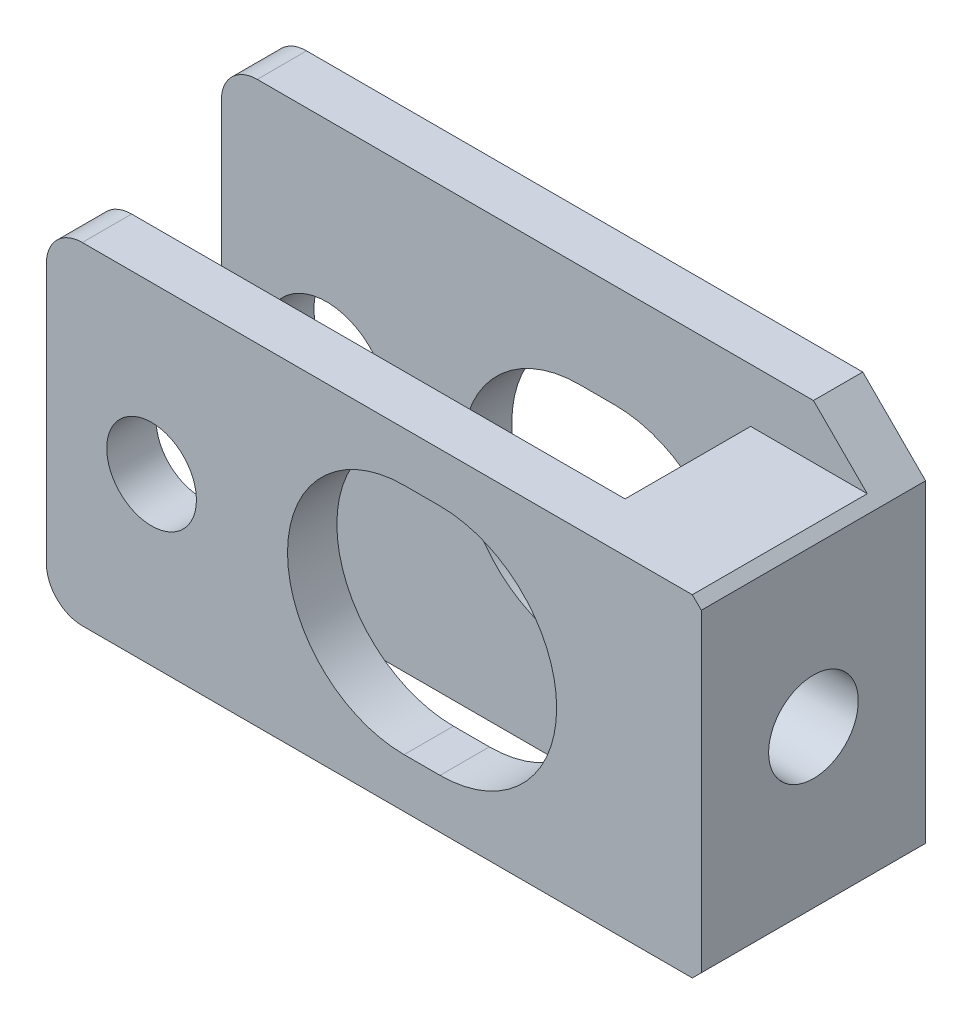
from build123d import *

# Parameters (mm, degrees)
SKETCH1_W           = 36.5
SKETCH1_H           = 18.5
SKETCH1_R           = 3.45
BOSS_EXTRUDE1_DEPTH = 12.5
SKETCH2_W           = 29.5
SKETCH2_H           = 7
CUT_EXTRUDE1_DEPTH  = 19.5
SKETCH3_R           = 3.45
SKETCH3_R_2         = 2.5
BOSS_EXTRUDE3_DEPTH = 2.75
SKETCH4_W           = 36.5
SKETCH4_H           = 2.75
BOSS_EXTRUDE4_DEPTH = 3
SKETCH5_W           = 36.5
SKETCH5_H           = 2.75
BOSS_EXTRUDE5_DEPTH = 3
CHAMFER1_SIZE       = 3.5
CHAMFER3_SIZE       = 3.5
CUT_EXTRUDE2_DEPTH  = 3
SKETCH7_R           = 2.5
CUT_EXTRUDE3_DEPTH  = 5
FILLET1_R           = 2


with BuildPart() as part:
    # Sketch1 → Boss-Extrude1 (new body)
    with BuildSketch(Plane.XY):
        with Locations((252.305597075, 227.81595418)):
            Rectangle(SKETCH1_W, SKETCH1_H)
        with Locations((239.915979082, 227.815953297)):
            Circle(SKETCH1_R, mode=Mode.SUBTRACT)
        with BuildLine():
            Line((253.99332378, 221.31595418), (255.99332378, 221.31595418))
            ThreePointArc((255.99332378, 221.31595418), (262.49332378, 227.81595418), (255.99332378, 234.31595418))
            Line((255.99332378, 234.31595418), (253.99332378, 234.31595418))
            ThreePointArc((253.99332378, 234.31595418), (247.49332378, 227.81595418), (253.99332378, 221.31595418))
        make_face(mode=Mode.SUBTRACT)
    extrude(amount=BOSS_EXTRUDE1_DEPTH)

    # Sketch2 → Cut-Extrude1 (cut, through all)
    with BuildSketch(Plane(origin=(0, 237.06595418, 0), x_dir=(1, 0, 0), z_dir=(0, 1, 0))):
        with Locations((248.805597075, -6.25)):
            Rectangle(SKETCH2_W, SKETCH2_H)
    extrude(amount=-CUT_EXTRUDE1_DEPTH, mode=Mode.SUBTRACT)

    # Sketch3 → Boss-Extrude3 (add)
    with BuildSketch(Plane.XY.offset(12.5)):
        with Locations((239.915979082, 227.815953297)):
            Circle(SKETCH3_R)
        with Locations((239.915979082, 227.815953297)):
            Circle(SKETCH3_R_2, mode=Mode.SUBTRACT)
    extrude(amount=-BOSS_EXTRUDE3_DEPTH)

    # Sketch4 → Boss-Extrude4 (add)
    with BuildSketch(Plane(origin=(0, 237.06595418, 0), x_dir=(1, 0, 0), z_dir=(0, 1, 0))):
        with Locations((252.305597075, -1.375)):
            Rectangle(SKETCH4_W, SKETCH4_H)
    extrude(amount=BOSS_EXTRUDE4_DEPTH)

    # Sketch5 → Boss-Extrude5 (add)
    with BuildSketch(Plane.XZ.offset(-218.56595418)):
        with Locations((252.305597075, 1.375)):
            Rectangle(SKETCH5_W, SKETCH5_H)
    extrude(amount=BOSS_EXTRUDE5_DEPTH)

    # Chamfer1
    chamfer1_edges = [part.edges().sort_by_distance(p)[0] for p in [
        (270.555597075, 215.56595418, 1.375),
    ]]
    chamfer(chamfer1_edges, length=CHAMFER1_SIZE)

    # Chamfer3
    chamfer3_edges = [part.edges().sort_by_distance(p)[0] for p in [
        (270.555597075, 240.06595418, 1.375),
    ]]
    chamfer(chamfer3_edges, length=CHAMFER3_SIZE)

    # Sketch6 → Cut-Extrude2 (cut)
    with BuildSketch(Plane.ZY.offset(-263.555597075)):
        Polygon((6.25, 224.005442403), (9.55, 225.910698292), (9.55, 229.721210068), (6.25, 231.626465957), (2.95, 229.721210068), (2.95, 225.910698292), align=None)
    extrude(amount=-CUT_EXTRUDE2_DEPTH, mode=Mode.SUBTRACT)

    # Sketch7 → Cut-Extrude3 (cut, through all)
    with BuildSketch(Plane.ZY.offset(-266.555597075)):
        with Locations((6.25, 227.81595418)):
            Circle(SKETCH7_R)
    extrude(amount=-CUT_EXTRUDE3_DEPTH, mode=Mode.SUBTRACT)

    # Fillet1
    fillet1_edges = [part.edges().sort_by_distance(p)[0] for p in [
        (234.055597075, 240.06595418, 1.375),
        (234.055597075, 218.56595418, 11.125),
        (234.055597075, 237.06595418, 11.125),
        (234.055597075, 215.56595418, 1.375),
    ]]
    fillet(fillet1_edges, radius=FILLET1_R)


solid = part.part
